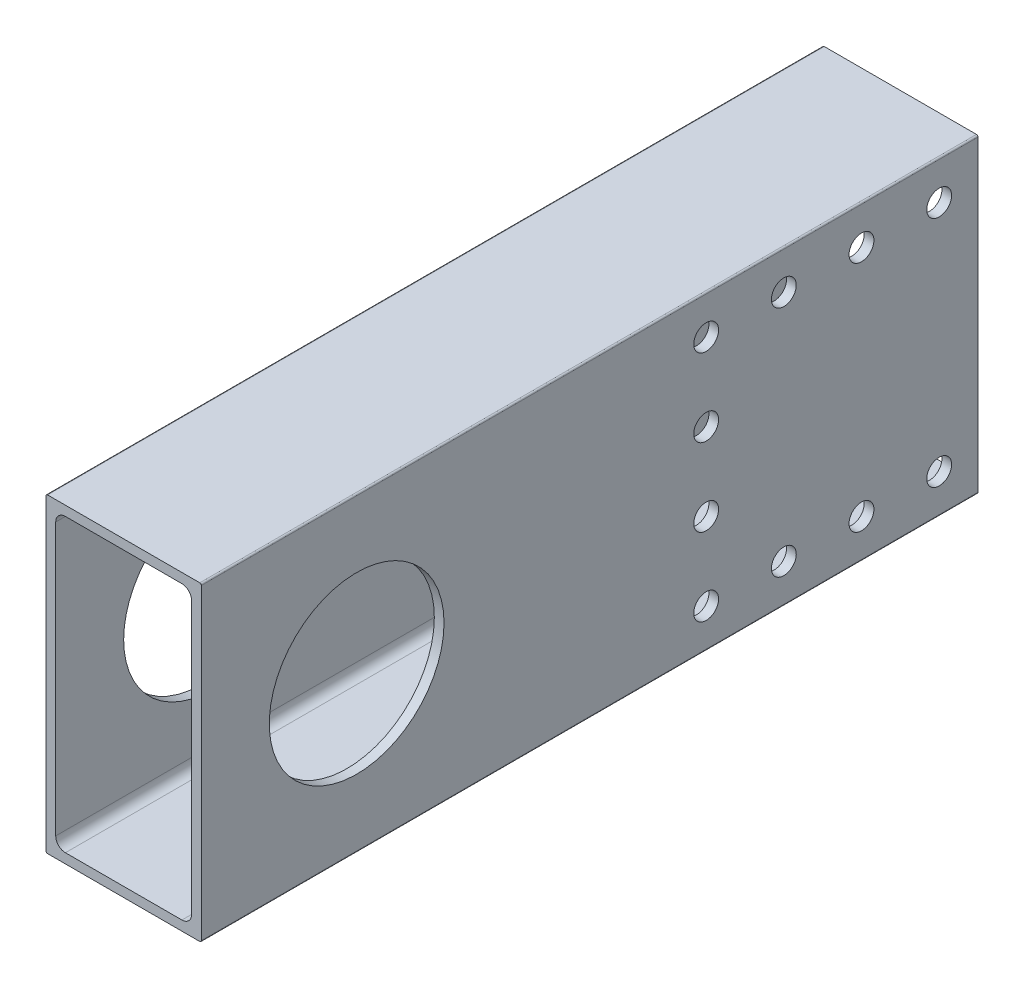
from build123d import *

# Parameters (mm, degrees)
BOSS_EXTRUDE1_DEPTH     = 127
SKETCH2_R               = 14.2875
CUT_EXTRUDE1_DEPTH      = 25.4
SKETCH3_R               = 2.032
CUT_EXTRUDE2_DEPTH      = 1
CUT_EXTRUDE2_DEPTH_BACK = 26.4


with BuildPart() as part:
    # Sketch1 → Boss-Extrude1 (new body)
    with BuildSketch(Plane(origin=(0, 0, 0), x_dir=(-1, 0, 0), z_dir=(0, 0, -1))):
        with BuildLine():
            Line((-12.7, 25.146), (-12.7, -25.146))
            ThreePointArc((-12.7, -25.146), (-12.625605122, -25.325605122), (-12.446, -25.4))
            Line((-12.446, -25.4), (12.446, -25.4))
            ThreePointArc((12.446, -25.4), (12.625605122, -25.325605122), (12.7, -25.146))
            Line((12.7, -25.146), (12.7, 25.146))
            ThreePointArc((12.7, 25.146), (12.625605122, 25.325605122), (12.446, 25.4))
            Line((12.446, 25.4), (-12.446, 25.4))
            ThreePointArc((-12.446, 25.4), (-12.625605122, 25.325605122), (-12.7, 25.146))
        make_face()
        with BuildLine():
            Line((-11.1125, -22.225), (-11.1125, 22.225))
            ThreePointArc((-11.1125, 22.225), (-10.647532015, 23.347532015), (-9.525, 23.8125))
            Line((-9.525, 23.8125), (9.525, 23.8125))
            ThreePointArc((9.525, 23.8125), (10.647532015, 23.347532015), (11.1125, 22.225))
            Line((11.1125, 22.225), (11.1125, -22.225))
            ThreePointArc((11.1125, -22.225), (10.647532015, -23.347532015), (9.525, -23.8125))
            Line((9.525, -23.8125), (-9.525, -23.8125))
            ThreePointArc((-9.525, -23.8125), (-10.647532015, -23.347532015), (-11.1125, -22.225))
        make_face(mode=Mode.SUBTRACT)
    extrude(amount=-BOSS_EXTRUDE1_DEPTH)

    # Sketch2 → Cut-Extrude1 (cut)
    with BuildSketch(Plane(origin=(12.7, 0, 0), x_dir=(0, 0, -1), z_dir=(1, 0, 0))):
        with Locations((-101.6, 0)):
            Circle(SKETCH2_R)
    extrude(amount=-CUT_EXTRUDE1_DEPTH, mode=Mode.SUBTRACT)

    # Sketch3 → Cut-Extrude2 (cut, two sides)
    with BuildSketch(Plane(origin=(12.7, 0, 0), x_dir=(0, 0, -1), z_dir=(1, 0, 0))) as cut_extrude2_sk:
        with Locations((-44.45, -19.05)):
            Circle(SKETCH3_R)
        with Locations((-44.45, -6.35)):
            Circle(SKETCH3_R)
        with Locations((-44.45, 19.05)):
            Circle(SKETCH3_R)
        with Locations((-31.75, 19.05)):
            Circle(SKETCH3_R)
        with Locations((-19.05, 19.05)):
            Circle(SKETCH3_R)
        with Locations((-6.35, 19.05)):
            Circle(SKETCH3_R)
        with Locations((-44.45, 6.35)):
            Circle(SKETCH3_R)
        with Locations((-31.75, -19.05)):
            Circle(SKETCH3_R)
        with Locations((-19.05, -19.05)):
            Circle(SKETCH3_R)
        with Locations((-6.35, -19.05)):
            Circle(SKETCH3_R)
    extrude(amount=CUT_EXTRUDE2_DEPTH, mode=Mode.SUBTRACT)
    extrude(cut_extrude2_sk.sketch, amount=-CUT_EXTRUDE2_DEPTH_BACK, mode=Mode.SUBTRACT)


solid = part.part
